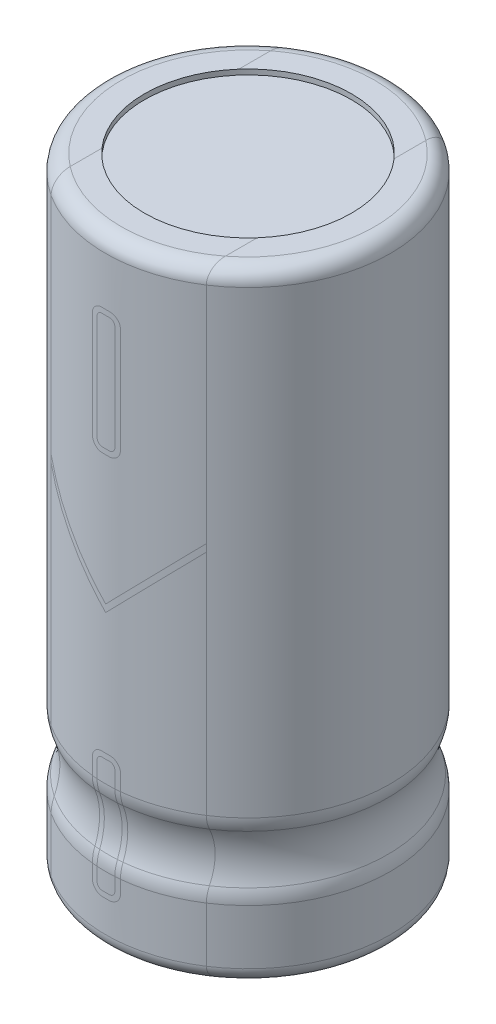
from build123d import *

# Parameters (mm, degrees)
SKETCH1_R           = 2.75
BOSS_EXTRUDE1_DEPTH = 12
FILLET2_R           = 0.3
FILLET3_R           = 0.3
FILLET4_R           = 0.7
SKETCH3_R           = 2
CUT_EXTRUDE1_DEPTH  = 0.1
SKETCH5_R           = 2
CUT_EXTRUDE3_DEPTH  = 0.1


with BuildPart() as part:
    # Sketch1 → Boss-Extrude1 (new body)
    with BuildSketch(Plane(origin=(0, 0, 0), x_dir=(1, 0, 0), z_dir=(0, 1, 0))):
        Circle(SKETCH1_R)
    extrude(amount=BOSS_EXTRUDE1_DEPTH)

    # Sketch2 → Cut-Revolve1 (revolve, cut)
    with BuildSketch(Plane.XY):
        with BuildLine():
            Line((2.75, 2.67418437), (2.75, 1.507628734))
            ThreePointArc((2.75, 1.507628734), (2.609122054, 2.090906552), (2.75, 2.67418437))
        make_face()
    revolve(axis=Axis((0, 0, 0), (0, 1, 0)), mode=Mode.SUBTRACT)

    # Fillet2
    fillet2_edges = [part.edges().sort_by_distance(p)[0] for p in [
        (-2.75, 12, 0),
    ]]
    fillet(fillet2_edges, radius=FILLET2_R)

    # Fillet3
    fillet3_edges = [part.edges().sort_by_distance(p)[0] for p in [
        (-2.75, 0, 0),
    ]]
    fillet(fillet3_edges, radius=FILLET3_R)

    # Fillet4
    fillet4_edges = [part.edges().sort_by_distance(p)[0] for p in [
        (-2.75, 1.507628734, 0),
        (-2.75, 2.67418437, 0),
    ]]
    fillet(fillet4_edges, radius=FILLET4_R)

    # Sketch3 → Cut-Extrude1 (cut)
    with BuildSketch(Plane(origin=(0, 12, 0), x_dir=(1, 0, 0), z_dir=(0, 1, 0))):
        Circle(SKETCH3_R)
    extrude(amount=-CUT_EXTRUDE1_DEPTH, mode=Mode.SUBTRACT)

    # Sketch5 → Cut-Extrude3 (cut)
    with BuildSketch(Plane.XZ):
        Circle(SKETCH5_R)
    extrude(amount=-CUT_EXTRUDE3_DEPTH, mode=Mode.SUBTRACT)


solid = part.part
